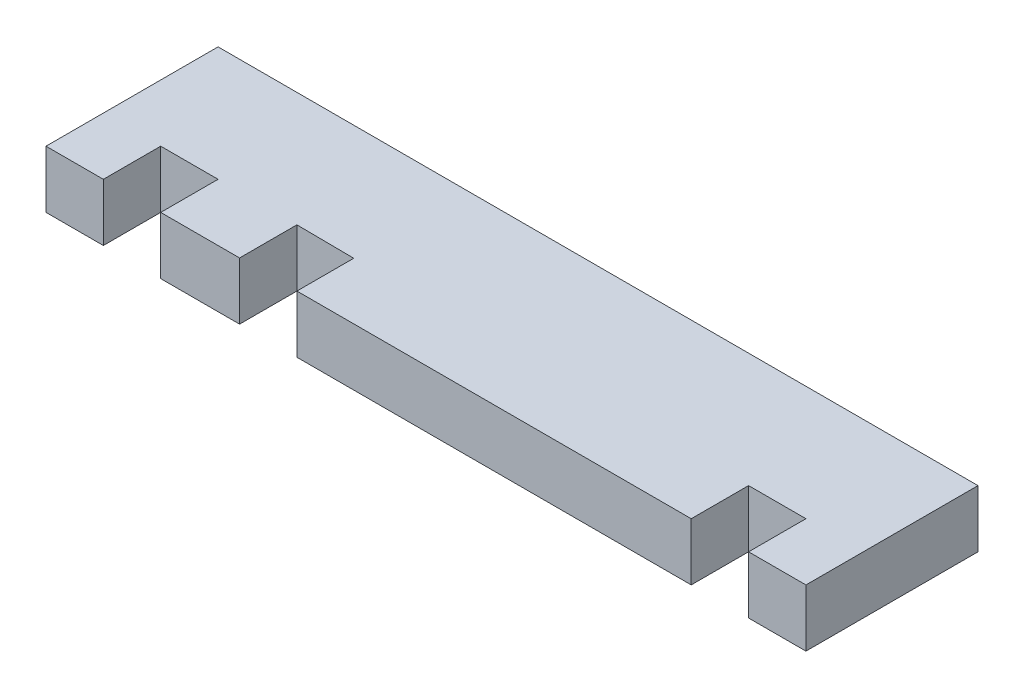
from build123d import *

# Parameters (mm, degrees)
BOSS_EXTRUDE1_DEPTH = 4


with BuildPart() as part:
    # Sketch1 → Boss-Extrude1 (new body)
    with BuildSketch(Plane(origin=(0, 0, 0), x_dir=(1, 0, 0), z_dir=(0, 1, 0))):
        Polygon((-26.5, 6), (26.5, 6), (26.5, -6), (22.5, -6), (22.5, -2), (18.5, -2), (18.5, -6), (-9, -6), (-9, -2.037735849), (-12.999821997, -2), (-12.999821997, -6), (-18.5, -6), (-18.5, -2), (-22.5, -2), (-22.5, -6), (-26.5, -6), align=None)
    extrude(amount=BOSS_EXTRUDE1_DEPTH)


solid = part.part
